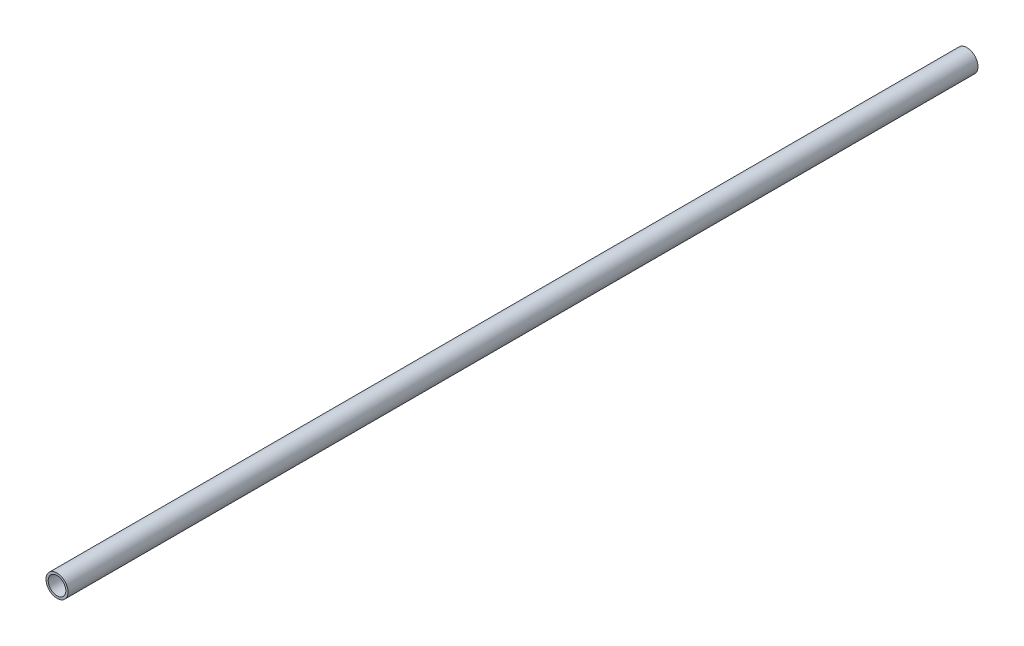
from build123d import *

# Parameters (mm, degrees)
SKETCH1_R           = 2.5
SKETCH1_R_2         = 2
BOSS_EXTRUDE1_DEPTH = 206.375


with BuildPart() as part:
    # Sketch1 → Boss-Extrude1 (new body)
    with BuildSketch(Plane.XY):
        Circle(SKETCH1_R)
        Circle(SKETCH1_R_2, mode=Mode.SUBTRACT)
    extrude(amount=BOSS_EXTRUDE1_DEPTH)


solid = part.part
